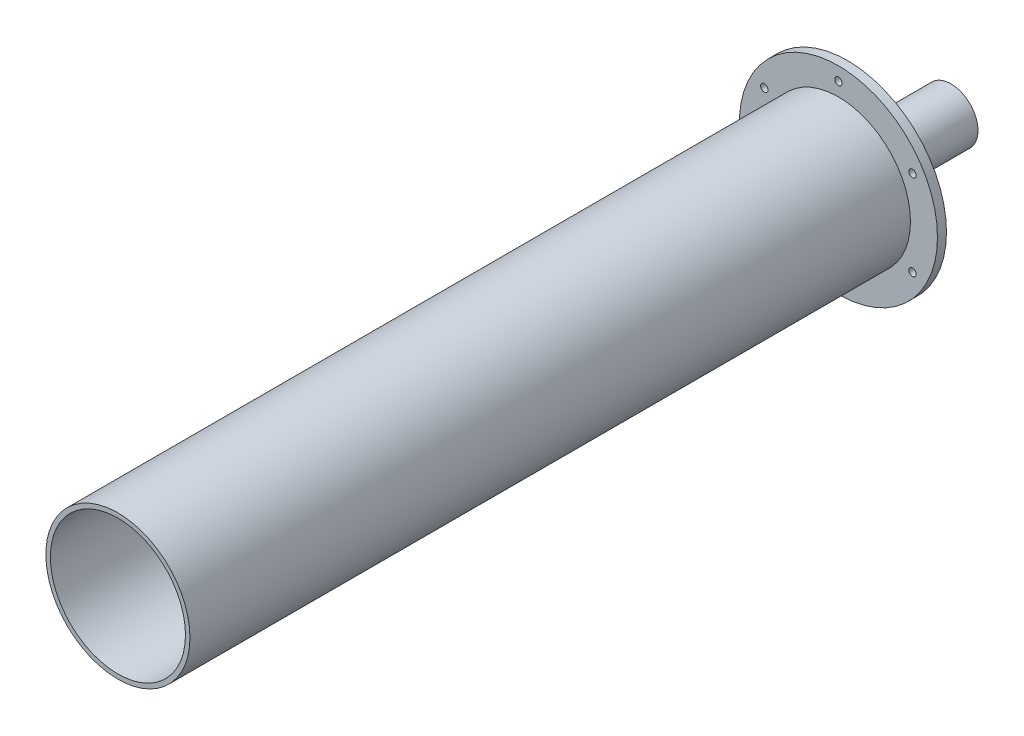
from build123d import *

# Parameters (mm, degrees)
SKETCH1_R            = 19.05
SKETCH1_R_2          = 15.875
EXTRUDE1_DEPTH       = 6.35
EXTRUDE1_DEPTH_BACK  = 73.025
SKETCH1_4_R          = 47.625
SKETCH1_4_R_2        = 19.05
EXTRUDE3_DEPTH       = 6.35
SKETCH1_6_R          = 69.85
SKETCH1_6_R_2        = 50.8
SKETCH1_6_R_3        = 2.5796875
EXTRUDE5_DEPTH       = 6.35
SKETCH1_9_R          = 50.8
SKETCH1_9_R_2        = 47.625
EXTRUDE8_DEPTH       = 5.08
SKETCH1_10_R         = 50.8
SKETCH1_10_R_2       = 47.625
CUT_EXTRUDE1_DEPTH   = 1.651
SKETCH1_13_R         = 2.5796875
EXTRUDE9_DEPTH       = 6.35
SKETCH1_14_R         = 2.5796875
CUT_EXTRUDE5_DEPTH   = 6.35
CIRPATTERN1_COUNT    = 6
SKETCH5_R            = 50.8
SKETCH5_R_2          = 47.625
EXTRUDE11_DEPTH      = 508
EXTRUDE11_DEPTH_BACK = 1.651


with BuildPart() as part:
    # Sketch1 → Extrude1 (new body, two sides)
    with BuildSketch(Plane.XY) as extrude1_sk:
        Circle(SKETCH1_R)
        Circle(SKETCH1_R_2, mode=Mode.SUBTRACT)
    extrude(amount=EXTRUDE1_DEPTH)
    extrude(extrude1_sk.sketch, amount=-EXTRUDE1_DEPTH_BACK)

    # Sketch1_4 → Extrude3 (add)
    with BuildSketch(Plane.XY):
        Circle(SKETCH1_4_R)
        Circle(SKETCH1_4_R_2, mode=Mode.SUBTRACT)
    extrude(amount=EXTRUDE3_DEPTH)



with BuildPart() as body_2:
    # Sketch1_6 → Extrude5 (new body)
    with BuildSketch(Plane.XY):
        Circle(SKETCH1_6_R)
        Circle(SKETCH1_6_R_2, mode=Mode.SUBTRACT)
        with Locations((0, 60.325)):
            Circle(SKETCH1_6_R_3, mode=Mode.SUBTRACT)
    extrude(amount=EXTRUDE5_DEPTH)


with BuildPart() as part_1:
    add(part.part)

    add(body_2.part)  # Extrude8 merges body 2
    # Sketch1_9 → Extrude8 (add)
    with BuildSketch(Plane.XY):
        Circle(SKETCH1_9_R)
        Circle(SKETCH1_9_R_2, mode=Mode.SUBTRACT)
    extrude(amount=EXTRUDE8_DEPTH)

    # Sketch1_10 → Cut-Extrude1 (cut)
    with BuildSketch(Plane.XY):
        Circle(SKETCH1_10_R)
        Circle(SKETCH1_10_R_2, mode=Mode.SUBTRACT)
    extrude(amount=CUT_EXTRUDE1_DEPTH, mode=Mode.SUBTRACT)

    # Sketch1_13 → Extrude9 (add)
    with BuildSketch(Plane.XY):
        with Locations((0, 60.325)):
            Circle(SKETCH1_13_R)
    extrude(amount=EXTRUDE9_DEPTH)

    # Sketch1_14 → Cut-Extrude5 (cut)
    with BuildSketch(Plane.XY):
        with Locations((0, 60.325)):
            Circle(SKETCH1_14_R)
    cut_extrude5 = extrude(amount=CUT_EXTRUDE5_DEPTH, mode=Mode.SUBTRACT)

    # CirPattern1: Cut-Extrude5 ×6 about axis
    cirpattern1_axis = Axis((0, 0, 0), (0, 0, 1))
    for i in range(1, CIRPATTERN1_COUNT):
        add(cut_extrude5.rotate(cirpattern1_axis, i * 360 / CIRPATTERN1_COUNT), mode=Mode.SUBTRACT)

    # Sketch5 → Extrude11 (add, two sides)
    with BuildSketch(Plane.XY.offset(6.35)) as extrude11_sk:
        Circle(SKETCH5_R)
        Circle(SKETCH5_R_2, mode=Mode.SUBTRACT)
    extrude(amount=EXTRUDE11_DEPTH)
    extrude(extrude11_sk.sketch, amount=-EXTRUDE11_DEPTH_BACK)


solid = part_1.part
